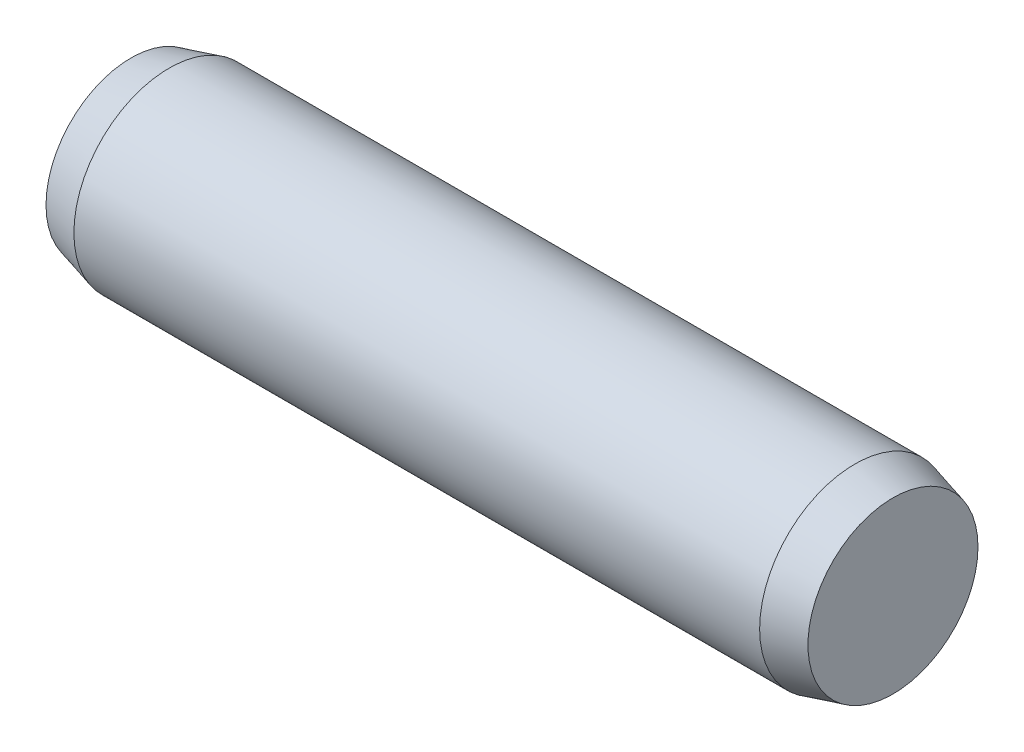
from build123d import *

# Parameters (mm, degrees)
SKETCH2_R           = 0.75
EXTRUDE1_DEPTH      = 2.7
EXTRUDE1_DEPTH_BACK = 2.7
SKETCH3_R           = 0.75
EXTRUDE2_DEPTH      = 0.3
EXTRUDE2_TAPER      = 15
SKETCH4_R           = 0.75
EXTRUDE3_DEPTH      = 0.3
EXTRUDE3_TAPER      = 15


with BuildPart() as part:
    # Sketch2 → Extrude1 (new body, two sides)
    with BuildSketch(Plane(origin=(0, 0, 0), x_dir=(0, 0, -1), z_dir=(1, 0, 0))) as extrude1_sk:
        Circle(SKETCH2_R)
    extrude(amount=EXTRUDE1_DEPTH)
    extrude(extrude1_sk.sketch, amount=-EXTRUDE1_DEPTH_BACK)

    # Sketch3 → Extrude2 (add)
    with BuildSketch(Plane(origin=(2.7, 0, 0), x_dir=(0, 0, -1), z_dir=(1, 0, 0))):
        Circle(SKETCH3_R)
    extrude(amount=EXTRUDE2_DEPTH, taper=EXTRUDE2_TAPER)

    # Sketch4 → Extrude3 (add)
    with BuildSketch(Plane.ZY.offset(2.7)):
        Circle(SKETCH4_R)
    extrude(amount=EXTRUDE3_DEPTH, taper=EXTRUDE3_TAPER)


solid = part.part
